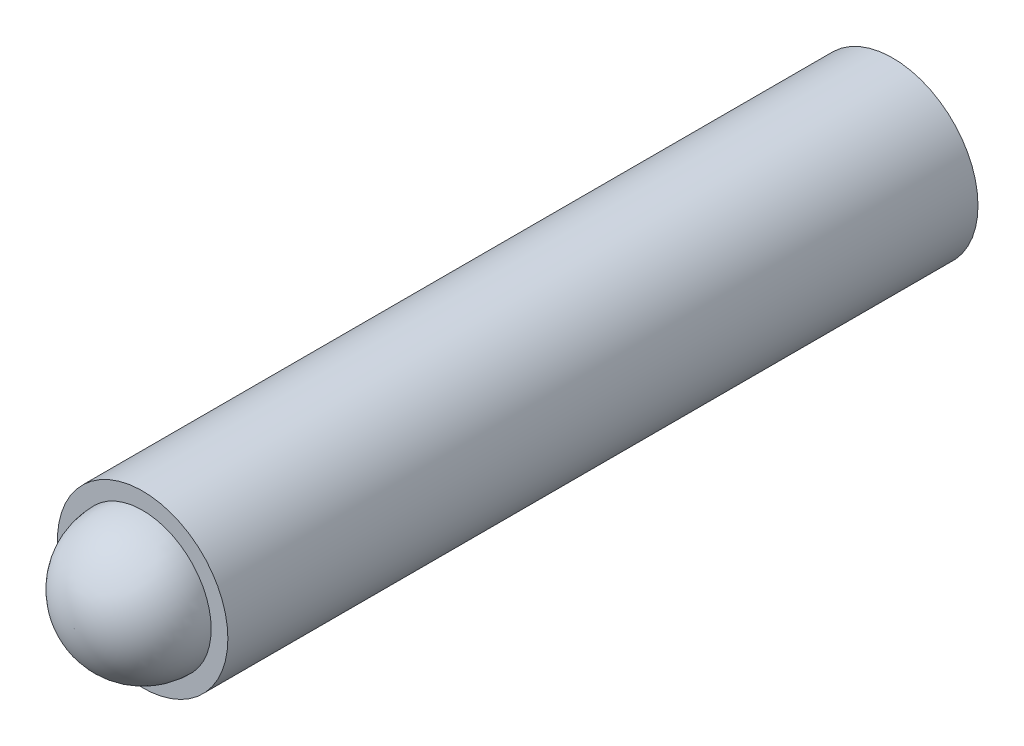
from build123d import *

# Parameters (mm, degrees)
SKETCH1_R           = 2.5
BOSS_EXTRUDE1_DEPTH = 24


with BuildPart() as part:
    # Sketch1 → Boss-Extrude1 (new body)
    with BuildSketch(Plane.XY):
        Circle(SKETCH1_R)
    extrude(amount=BOSS_EXTRUDE1_DEPTH)

    # Sketch2 → Cut-Revolve6 (revolve, cut)
    with BuildSketch(Plane(origin=(0, 0, 0), x_dir=(1, 0, 0), z_dir=(0, 1, 0))):
        with BuildLine():
            Line((2.01, -22), (2.5, -22))
            Line((2.5, -22), (2.5, -24))
            Line((2.5, -24), (0.01, -24))
            ThreePointArc((0.01, -24), (1.424213562, -23.414213562), (2.01, -22))
        make_face()
    revolve(axis=Axis((0, 0, 24), (0, 0, -1)), mode=Mode.SUBTRACT)


solid = part.part
